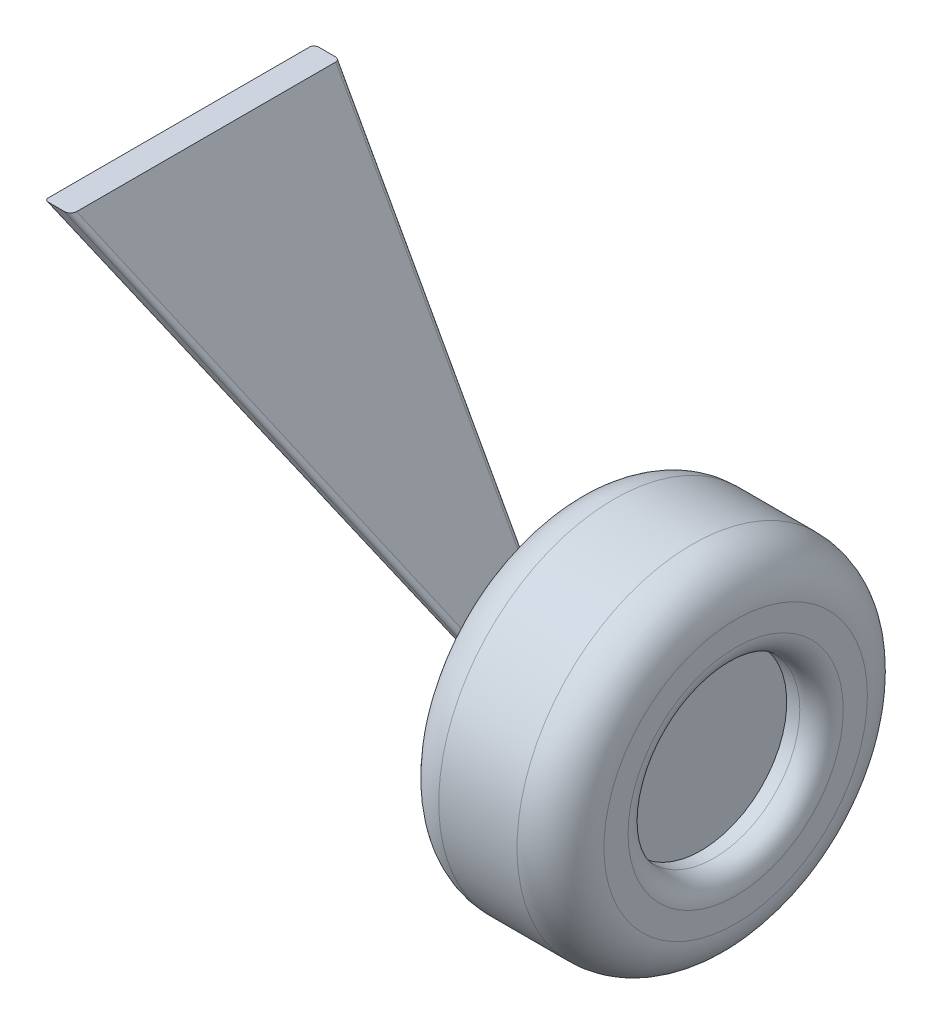
from build123d import *

# Parameters (mm, degrees)
SKETCH1_R           = 201.5
SKETCH1_R_2         = 98.768091278
BOSS_EXTRUDE1_DEPTH = 190
SKETCH2_R           = 98.768091278
BOSS_EXTRUDE2_DEPTH = 150
FILLET1_R           = 50
FILLET2_R           = 25
BOSS_EXTRUDE3_DEPTH = 310
CUT_EXTRUDE1_DEPTH  = 300
FILLET3_R           = 5


with BuildPart() as part:
    # Sketch1 → Boss-Extrude1 (new body)
    with BuildSketch(Plane(origin=(0, 0, 0), x_dir=(0, 0, -1), z_dir=(1, 0, 0))):
        Circle(SKETCH1_R)
        Circle(SKETCH1_R_2, mode=Mode.SUBTRACT)
    extrude(amount=BOSS_EXTRUDE1_DEPTH)

    # Sketch2 → Boss-Extrude2 (add)
    with BuildSketch(Plane.ZY):
        Circle(SKETCH2_R)
    extrude(amount=-BOSS_EXTRUDE2_DEPTH)

    # Fillet1
    fillet1_edges = [part.edges().sort_by_distance(p)[0] for p in [
        (0, 0, 201.5),
        (190, 0, 201.5),
    ]]
    fillet(fillet1_edges, radius=FILLET1_R)

    # Fillet2
    fillet2_edges = [part.edges().sort_by_distance(p)[0] for p in [
        (190, 0, 98.768091278),
    ]]
    fillet(fillet2_edges, radius=FILLET2_R)

    # Sketch3 → Boss-Extrude3 (add)
    with BuildSketch(Plane.XY):
        Polygon((0, -30), (0, 0), (-265, 481.949167444), (-295, 481.949167444), align=None)
    extrude(amount=BOSS_EXTRUDE3_DEPTH)

    # Sketch4 → Cut-Extrude1 (cut)
    with BuildSketch(Plane.ZY.offset(300)):
        Polygon((40, -30), (310, 481.949167444), (310, -30), align=None)
    extrude(amount=-CUT_EXTRUDE1_DEPTH, mode=Mode.SUBTRACT)

    # Fillet3
    fillet3_edges = [part.edges().sort_by_distance(p)[0] for p in [
        (-132.5, 240.974583722, 0),
        (-147.5, 225.974583722, 0),
        (-132.5, 240.974583722, 182.910941667),
        (-147.5, 225.974583722, 175),
    ]]
    fillet(fillet3_edges, radius=FILLET3_R)


solid = part.part
